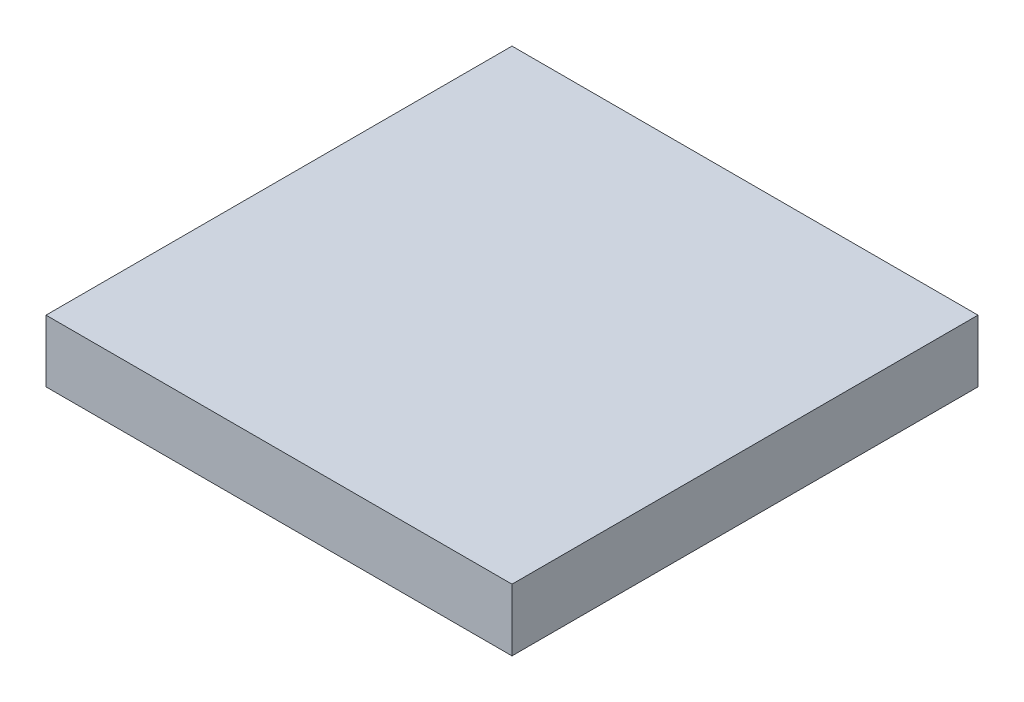
from build123d import *

# Parameters (mm, degrees)
SKETCH1_W           = 15
SKETCH1_H           = 15
BOSS_EXTRUDE1_DEPTH = 2


with BuildPart() as part:
    # Sketch1 → Boss-Extrude1 (new body)
    with BuildSketch(Plane(origin=(0, 0, 0), x_dir=(1, 0, 0), z_dir=(0, 1, 0))):
        with Locations((7.5, 7.5)):
            Rectangle(SKETCH1_W, SKETCH1_H)
    extrude(amount=BOSS_EXTRUDE1_DEPTH)


solid = part.part
